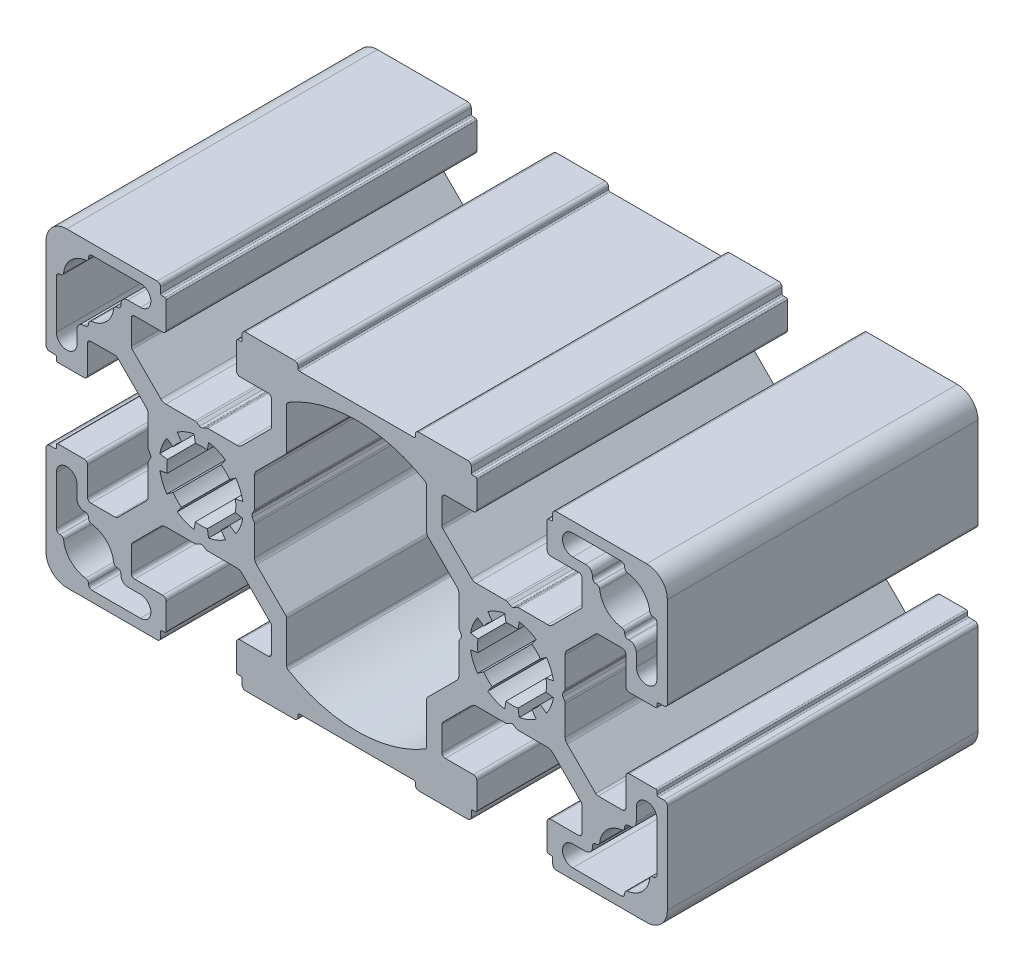
from build123d import *

# Parameters (mm, degrees)
EXTRUDE_2_DEPTH = 45


with BuildPart() as part:
    # Эскиз1 → Бобышка-Вытянуть2 (new body)
    with BuildSketch(Plane.XY):
        with BuildLine():
            Line((-35.141853673, 36.152210307), (-35.141853673, 40.388068593))
            ThreePointArc((-35.141853673, 40.388068593), (-35.21797414, 40.770752026), (-35.434746892, 41.095175374))
            Line((-35.434746892, 41.095175374), (-37.681504654, 43.341933137))
            Line((-37.681504654, 43.341933137), (-39.566246974, 45.226675456))
            ThreePointArc((-39.566246974, 45.226675456), (-39.728458648, 45.335061832), (-39.919800364, 45.373122066))
            Line((-39.919800364, 45.373122066), (-43.441373239, 45.373122066))
            ThreePointArc((-43.441373239, 45.373122066), (-43.79492663, 45.226675456), (-43.941373239, 44.873122066))
            Line((-43.941373239, 44.873122066), (-43.941373239, 40.823122066))
            ThreePointArc((-43.941373239, 40.823122066), (-44.087819849, 40.469568675), (-44.441373239, 40.323122066))
            Line((-44.441373239, 40.323122066), (-48.241373239, 40.323122066))
            ThreePointArc((-48.241373239, 40.323122066), (-48.382794596, 40.381700709), (-48.441373239, 40.523122066))
            Line((-48.441373239, 40.523122066), (-48.441373239, 40.923122066))
            ThreePointArc((-48.441373239, 40.923122066), (-48.499951883, 41.064543422), (-48.641373239, 41.123122066))
            Line((-48.641373239, 41.123122066), (-49.441373239, 41.123122066))
            ThreePointArc((-49.441373239, 41.123122066), (-49.79492663, 41.269568675), (-49.941373239, 41.623122066))
            Line((-49.941373239, 41.623122066), (-49.941373239, 54.723122066))
            ThreePointArc((-49.941373239, 54.723122066), (-49.062693583, 56.844442409), (-46.941373239, 57.723122066))
            Line((-46.941373239, 57.723122066), (-33.841373239, 57.723122066))
            ThreePointArc((-33.841373239, 57.723122066), (-33.487819849, 57.576675456), (-33.341373239, 57.223122066))
            Line((-33.341373239, 57.223122066), (-33.341373239, 56.423122066))
            ThreePointArc((-33.341373239, 56.423122066), (-33.282794596, 56.281700709), (-33.141373239, 56.223122066))
            Line((-33.141373239, 56.223122066), (-32.741373239, 56.223122066))
            ThreePointArc((-32.741373239, 56.223122066), (-32.599951883, 56.164543422), (-32.541373239, 56.023122066))
            Line((-32.541373239, 56.023122066), (-32.541373239, 52.223122066))
            ThreePointArc((-32.541373239, 52.223122066), (-32.687819849, 51.869568675), (-33.041373239, 51.723122066))
            Line((-33.041373239, 51.723122066), (-37.091373239, 51.723122066))
            ThreePointArc((-37.091373239, 51.723122066), (-37.44492663, 51.576675456), (-37.591373239, 51.223122066))
            Line((-37.591373239, 51.223122066), (-37.591373239, 47.70154919))
            ThreePointArc((-37.591373239, 47.70154919), (-37.553313006, 47.510207474), (-37.44492663, 47.3479958))
            Line((-37.44492663, 47.3479958), (-35.560184311, 45.463253481))
            Line((-35.560184311, 45.463253481), (-33.313426548, 43.216495718))
            ThreePointArc((-33.313426548, 43.216495718), (-32.989003199, 42.999722967), (-32.606319767, 42.923602499))
            Line((-32.606319767, 42.923602499), (-28.370461481, 42.923602499))
            ThreePointArc((-28.370461481, 42.923602499), (-28.241051958, 42.906565412), (-28.120461481, 42.856615201))
            Line((-28.120461481, 42.856615201), (-27.691373239, 42.608880989))
            ThreePointArc((-27.691373239, 42.608880989), (-27.441373239, 42.541893691), (-27.191373239, 42.608880989))
            Line((-27.191373239, 42.608880989), (-26.762284998, 42.856615201))
            ThreePointArc((-26.762284998, 42.856615201), (-26.64169452, 42.906565412), (-26.512284998, 42.923602499))
            Line((-26.512284998, 42.923602499), (-22.276426712, 42.923602499))
            ThreePointArc((-22.276426712, 42.923602499), (-21.89374328, 42.999722967), (-21.569319931, 43.216495718))
            Line((-21.569319931, 43.216495718), (-19.322562168, 45.463253481))
            Line((-19.322562168, 45.463253481), (-17.437819849, 47.3479958))
            ThreePointArc((-17.437819849, 47.3479958), (-17.329433473, 47.510207474), (-17.291373239, 47.70154919))
            Line((-17.291373239, 47.70154919), (-17.291373239, 51.223122066))
            ThreePointArc((-17.291373239, 51.223122066), (-17.437819849, 51.576675456), (-17.791373239, 51.723122066))
            Line((-17.791373239, 51.723122066), (-21.841373239, 51.723122066))
            ThreePointArc((-21.841373239, 51.723122066), (-22.19492663, 51.869568675), (-22.341373239, 52.223122066))
            Line((-22.341373239, 52.223122066), (-22.341373239, 56.023122066))
            ThreePointArc((-22.341373239, 56.023122066), (-22.282794596, 56.164543422), (-22.141373239, 56.223122066))
            Line((-22.141373239, 56.223122066), (-21.741373239, 56.223122066))
            ThreePointArc((-21.741373239, 56.223122066), (-21.599951883, 56.281700709), (-21.541373239, 56.423122066))
            Line((-21.541373239, 56.423122066), (-21.541373239, 57.223122066))
            ThreePointArc((-21.541373239, 57.223122066), (-21.39492663, 57.576675456), (-21.041373239, 57.723122066))
            Line((-21.041373239, 57.723122066), (-13.941373239, 57.723122066))
            ThreePointArc((-13.941373239, 57.723122066), (-13.587819849, 57.576675456), (-13.441373239, 57.223122066))
            Line((-13.441373239, 57.223122066), (-13.441373239, 56.923122066))
            ThreePointArc((-13.441373239, 56.923122066), (-13.382794596, 56.781700709), (-13.241373239, 56.723122066))
            Line((-13.241373239, 56.723122066), (3.358626761, 56.723122066))
            ThreePointArc((3.358626761, 56.723122066), (3.500048117, 56.781700709), (3.558626761, 56.923122066))
            Line((3.558626761, 56.923122066), (3.558626761, 57.223122066))
            ThreePointArc((3.558626761, 57.223122066), (3.70507337, 57.576675456), (4.058626761, 57.723122066))
            Line((4.058626761, 57.723122066), (11.158626761, 57.723122066))
            ThreePointArc((11.158626761, 57.723122066), (11.512180151, 57.576675456), (11.658626761, 57.223122066))
            Line((11.658626761, 57.223122066), (11.658626761, 56.423122066))
            ThreePointArc((11.658626761, 56.423122066), (11.717205404, 56.281700709), (11.858626761, 56.223122066))
            Line((11.858626761, 56.223122066), (12.258626761, 56.223122066))
            ThreePointArc((12.258626761, 56.223122066), (12.400048117, 56.164543422), (12.458626761, 56.023122066))
            Line((12.458626761, 56.023122066), (12.458626761, 52.223122066))
            ThreePointArc((12.458626761, 52.223122066), (12.312180151, 51.869568675), (11.958626761, 51.723122066))
            Line((11.958626761, 51.723122066), (7.908626761, 51.723122066))
            ThreePointArc((7.908626761, 51.723122066), (7.55507337, 51.576675456), (7.408626761, 51.223122066))
            Line((7.408626761, 51.223122066), (7.408626761, 47.70154919))
            ThreePointArc((7.408626761, 47.70154919), (7.446686994, 47.510207474), (7.55507337, 47.3479958))
            Line((7.55507337, 47.3479958), (9.439815689, 45.463253481))
            Line((9.439815689, 45.463253481), (11.686573452, 43.216495718))
            ThreePointArc((11.686573452, 43.216495718), (12.010996801, 42.999722967), (12.393680233, 42.923602499))
            Line((12.393680233, 42.923602499), (16.629538519, 42.923602499))
            ThreePointArc((16.629538519, 42.923602499), (16.758948042, 42.906565412), (16.879538519, 42.856615201))
            Line((16.879538519, 42.856615201), (17.308626761, 42.608880989))
            ThreePointArc((17.308626761, 42.608880989), (17.558626761, 42.541893691), (17.808626761, 42.608880989))
            Line((17.808626761, 42.608880989), (18.237715002, 42.856615201))
            ThreePointArc((18.237715002, 42.856615201), (18.35830548, 42.906565412), (18.487715002, 42.923602499))
            Line((18.487715002, 42.923602499), (22.723573288, 42.923602499))
            ThreePointArc((22.723573288, 42.923602499), (23.10625672, 42.999722967), (23.430680069, 43.216495718))
            Line((23.430680069, 43.216495718), (25.677437832, 45.463253481))
            Line((25.677437832, 45.463253481), (27.562180151, 47.3479958))
            ThreePointArc((27.562180151, 47.3479958), (27.670566527, 47.510207474), (27.708626761, 47.70154919))
            Line((27.708626761, 47.70154919), (27.708626761, 51.223122066))
            ThreePointArc((27.708626761, 51.223122066), (27.562180151, 51.576675456), (27.208626761, 51.723122066))
            Line((27.208626761, 51.723122066), (23.158626761, 51.723122066))
            ThreePointArc((23.158626761, 51.723122066), (22.80507337, 51.869568675), (22.658626761, 52.223122066))
            Line((22.658626761, 52.223122066), (22.658626761, 56.023122066))
            ThreePointArc((22.658626761, 56.023122066), (22.717205404, 56.164543422), (22.858626761, 56.223122066))
            Line((22.858626761, 56.223122066), (23.258626761, 56.223122066))
            ThreePointArc((23.258626761, 56.223122066), (23.400048117, 56.281700709), (23.458626761, 56.423122066))
            Line((23.458626761, 56.423122066), (23.458626761, 57.223122066))
            ThreePointArc((23.458626761, 57.223122066), (23.60507337, 57.576675456), (23.958626761, 57.723122066))
            Line((23.958626761, 57.723122066), (37.058626761, 57.723122066))
            ThreePointArc((37.058626761, 57.723122066), (39.179947104, 56.844442409), (40.058626761, 54.723122066))
            Line((40.058626761, 54.723122066), (40.058626761, 41.623122066))
            ThreePointArc((40.058626761, 41.623122066), (39.912180151, 41.269568675), (39.558626761, 41.123122066))
            Line((39.558626761, 41.123122066), (38.758626761, 41.123122066))
            ThreePointArc((38.758626761, 41.123122066), (38.617205404, 41.064543422), (38.558626761, 40.923122066))
            Line((38.558626761, 40.923122066), (38.558626761, 40.523122066))
            ThreePointArc((38.558626761, 40.523122066), (38.500048117, 40.381700709), (38.358626761, 40.323122066))
            Line((38.358626761, 40.323122066), (34.558626761, 40.323122066))
            ThreePointArc((34.558626761, 40.323122066), (34.20507337, 40.469568675), (34.058626761, 40.823122066))
            Line((34.058626761, 40.823122066), (34.058626761, 44.873122066))
            ThreePointArc((34.058626761, 44.873122066), (33.912180151, 45.226675456), (33.558626761, 45.373122066))
            Line((33.558626761, 45.373122066), (30.037053885, 45.373122066))
            ThreePointArc((30.037053885, 45.373122066), (29.845712169, 45.335061832), (29.683500495, 45.226675456))
            Line((29.683500495, 45.226675456), (27.798758175, 43.341933137))
            Line((27.798758175, 43.341933137), (25.552000413, 41.095175374))
            ThreePointArc((25.552000413, 41.095175374), (25.335227661, 40.770752026), (25.259107194, 40.388068593))
            Line((25.259107194, 40.388068593), (25.259107194, 36.152210307))
            ThreePointArc((25.259107194, 36.152210307), (25.242070107, 36.022800785), (25.192119896, 35.902210307))
            Line((25.192119896, 35.902210307), (24.944385684, 35.473122066))
            ThreePointArc((24.944385684, 35.473122066), (24.877398386, 35.223122066), (24.944385684, 34.973122066))
            Line((24.944385684, 34.973122066), (25.192119896, 34.544033824))
            ThreePointArc((25.192119896, 34.544033824), (25.242070107, 34.423443347), (25.259107194, 34.294033824))
            Line((25.259107194, 34.294033824), (25.259107194, 30.058175538))
            ThreePointArc((25.259107194, 30.058175538), (25.335227661, 29.675492106), (25.552000413, 29.351068757))
            Line((25.552000413, 29.351068757), (27.798758175, 27.104310994))
            Line((27.798758175, 27.104310994), (29.683500495, 25.219568675))
            ThreePointArc((29.683500495, 25.219568675), (29.845712169, 25.111182299), (30.037053885, 25.073122066))
            Line((30.037053885, 25.073122066), (33.558626761, 25.073122066))
            ThreePointArc((33.558626761, 25.073122066), (33.912180151, 25.219568675), (34.058626761, 25.573122066))
            Line((34.058626761, 25.573122066), (34.058626761, 29.623122066))
            ThreePointArc((34.058626761, 29.623122066), (34.20507337, 29.976675456), (34.558626761, 30.123122066))
            Line((34.558626761, 30.123122066), (38.358626761, 30.123122066))
            ThreePointArc((38.358626761, 30.123122066), (38.500048117, 30.064543422), (38.558626761, 29.923122066))
            Line((38.558626761, 29.923122066), (38.558626761, 29.523122066))
            ThreePointArc((38.558626761, 29.523122066), (38.617205404, 29.381700709), (38.758626761, 29.323122066))
            Line((38.758626761, 29.323122066), (39.558626761, 29.323122066))
            ThreePointArc((39.558626761, 29.323122066), (39.912180151, 29.176675456), (40.058626761, 28.823122066))
            Line((40.058626761, 28.823122066), (40.058626761, 15.723122066))
            ThreePointArc((40.058626761, 15.723122066), (39.179947104, 13.601801722), (37.058626761, 12.723122066))
            Line((37.058626761, 12.723122066), (23.958626761, 12.723122066))
            ThreePointArc((23.958626761, 12.723122066), (23.60507337, 12.869568675), (23.458626761, 13.223122066))
            Line((23.458626761, 13.223122066), (23.458626761, 14.023122066))
            ThreePointArc((23.458626761, 14.023122066), (23.400048117, 14.164543422), (23.258626761, 14.223122066))
            Line((23.258626761, 14.223122066), (22.858626761, 14.223122066))
            ThreePointArc((22.858626761, 14.223122066), (22.717205404, 14.281700709), (22.658626761, 14.423122066))
            Line((22.658626761, 14.423122066), (22.658626761, 18.223122066))
            ThreePointArc((22.658626761, 18.223122066), (22.80507337, 18.576675456), (23.158626761, 18.723122066))
            Line((23.158626761, 18.723122066), (27.208626761, 18.723122066))
            ThreePointArc((27.208626761, 18.723122066), (27.562180151, 18.869568675), (27.708626761, 19.223122066))
            Line((27.708626761, 19.223122066), (27.708626761, 22.744694941))
            ThreePointArc((27.708626761, 22.744694941), (27.670566527, 22.936036657), (27.562180151, 23.098248332))
            Line((27.562180151, 23.098248332), (25.677437832, 24.982990651))
            Line((25.677437832, 24.982990651), (23.430680069, 27.229748413))
            ThreePointArc((23.430680069, 27.229748413), (23.10625672, 27.446521165), (22.723573288, 27.522641632))
            Line((22.723573288, 27.522641632), (18.487715002, 27.522641632))
            ThreePointArc((18.487715002, 27.522641632), (18.35830548, 27.539678719), (18.237715002, 27.58962893))
            Line((18.237715002, 27.58962893), (17.808626761, 27.837363142))
            ThreePointArc((17.808626761, 27.837363142), (17.558626761, 27.90435044), (17.308626761, 27.837363142))
            Line((17.308626761, 27.837363142), (16.879538519, 27.58962893))
            ThreePointArc((16.879538519, 27.58962893), (16.758948042, 27.539678719), (16.629538519, 27.522641632))
            Line((16.629538519, 27.522641632), (12.393680233, 27.522641632))
            ThreePointArc((12.393680233, 27.522641632), (12.010996801, 27.446521165), (11.686573452, 27.229748413))
            Line((11.686573452, 27.229748413), (9.439815689, 24.982990651))
            Line((9.439815689, 24.982990651), (7.55507337, 23.098248332))
            ThreePointArc((7.55507337, 23.098248332), (7.446686994, 22.936036657), (7.408626761, 22.744694941))
            Line((7.408626761, 22.744694941), (7.408626761, 19.223122066))
            ThreePointArc((7.408626761, 19.223122066), (7.55507337, 18.869568675), (7.908626761, 18.723122066))
            Line((7.908626761, 18.723122066), (11.958626761, 18.723122066))
            ThreePointArc((11.958626761, 18.723122066), (12.312180151, 18.576675456), (12.458626761, 18.223122066))
            Line((12.458626761, 18.223122066), (12.458626761, 14.423122066))
            ThreePointArc((12.458626761, 14.423122066), (12.400048117, 14.281700709), (12.258626761, 14.223122066))
            Line((12.258626761, 14.223122066), (11.858626761, 14.223122066))
            ThreePointArc((11.858626761, 14.223122066), (11.717205404, 14.164543422), (11.658626761, 14.023122066))
            Line((11.658626761, 14.023122066), (11.658626761, 13.223122066))
            ThreePointArc((11.658626761, 13.223122066), (11.512180151, 12.869568675), (11.158626761, 12.723122066))
            Line((11.158626761, 12.723122066), (4.058626761, 12.723122066))
            ThreePointArc((4.058626761, 12.723122066), (3.70507337, 12.869568675), (3.558626761, 13.223122066))
            Line((3.558626761, 13.223122066), (3.558626761, 13.523122066))
            ThreePointArc((3.558626761, 13.523122066), (3.500048117, 13.664543422), (3.358626761, 13.723122066))
            Line((3.358626761, 13.723122066), (-13.241373239, 13.723122066))
            ThreePointArc((-13.241373239, 13.723122066), (-13.382794596, 13.664543422), (-13.441373239, 13.523122066))
            Line((-13.441373239, 13.523122066), (-13.441373239, 13.223122066))
            ThreePointArc((-13.441373239, 13.223122066), (-13.587819849, 12.869568675), (-13.941373239, 12.723122066))
            Line((-13.941373239, 12.723122066), (-21.041373239, 12.723122066))
            ThreePointArc((-21.041373239, 12.723122066), (-21.39492663, 12.869568675), (-21.541373239, 13.223122066))
            Line((-21.541373239, 13.223122066), (-21.541373239, 14.023122066))
            ThreePointArc((-21.541373239, 14.023122066), (-21.599951883, 14.164543422), (-21.741373239, 14.223122066))
            Line((-21.741373239, 14.223122066), (-22.141373239, 14.223122066))
            ThreePointArc((-22.141373239, 14.223122066), (-22.282794596, 14.281700709), (-22.341373239, 14.423122066))
            Line((-22.341373239, 14.423122066), (-22.341373239, 18.223122066))
            ThreePointArc((-22.341373239, 18.223122066), (-22.19492663, 18.576675456), (-21.841373239, 18.723122066))
            Line((-21.841373239, 18.723122066), (-17.791373239, 18.723122066))
            ThreePointArc((-17.791373239, 18.723122066), (-17.437819849, 18.869568675), (-17.291373239, 19.223122066))
            Line((-17.291373239, 19.223122066), (-17.291373239, 22.744694941))
            ThreePointArc((-17.291373239, 22.744694941), (-17.329433473, 22.936036657), (-17.437819849, 23.098248332))
            Line((-17.437819849, 23.098248332), (-19.322562168, 24.982990651))
            Line((-19.322562168, 24.982990651), (-21.569319931, 27.229748413))
            ThreePointArc((-21.569319931, 27.229748413), (-21.89374328, 27.446521165), (-22.276426712, 27.522641632))
            Line((-22.276426712, 27.522641632), (-26.512284998, 27.522641632))
            ThreePointArc((-26.512284998, 27.522641632), (-26.64169452, 27.539678719), (-26.762284998, 27.58962893))
            Line((-26.762284998, 27.58962893), (-27.191373239, 27.837363142))
            ThreePointArc((-27.191373239, 27.837363142), (-27.441373239, 27.90435044), (-27.691373239, 27.837363142))
            Line((-27.691373239, 27.837363142), (-28.120461481, 27.58962893))
            ThreePointArc((-28.120461481, 27.58962893), (-28.241051958, 27.539678719), (-28.370461481, 27.522641632))
            Line((-28.370461481, 27.522641632), (-32.606319767, 27.522641632))
            ThreePointArc((-32.606319767, 27.522641632), (-32.989003199, 27.446521165), (-33.313426548, 27.229748413))
            Line((-33.313426548, 27.229748413), (-35.560184311, 24.982990651))
            Line((-35.560184311, 24.982990651), (-37.44492663, 23.098248332))
            ThreePointArc((-37.44492663, 23.098248332), (-37.553313006, 22.936036657), (-37.591373239, 22.744694941))
            Line((-37.591373239, 22.744694941), (-37.591373239, 19.223122066))
            ThreePointArc((-37.591373239, 19.223122066), (-37.44492663, 18.869568675), (-37.091373239, 18.723122066))
            Line((-37.091373239, 18.723122066), (-33.041373239, 18.723122066))
            ThreePointArc((-33.041373239, 18.723122066), (-32.687819849, 18.576675456), (-32.541373239, 18.223122066))
            Line((-32.541373239, 18.223122066), (-32.541373239, 14.423122066))
            ThreePointArc((-32.541373239, 14.423122066), (-32.599951883, 14.281700709), (-32.741373239, 14.223122066))
            Line((-32.741373239, 14.223122066), (-33.141373239, 14.223122066))
            ThreePointArc((-33.141373239, 14.223122066), (-33.282794596, 14.164543422), (-33.341373239, 14.023122066))
            Line((-33.341373239, 14.023122066), (-33.341373239, 13.223122066))
            ThreePointArc((-33.341373239, 13.223122066), (-33.487819849, 12.869568675), (-33.841373239, 12.723122066))
            Line((-33.841373239, 12.723122066), (-46.941373239, 12.723122066))
            ThreePointArc((-46.941373239, 12.723122066), (-49.062693583, 13.601801722), (-49.941373239, 15.723122066))
            Line((-49.941373239, 15.723122066), (-49.941373239, 28.823122066))
            ThreePointArc((-49.941373239, 28.823122066), (-49.79492663, 29.176675456), (-49.441373239, 29.323122066))
            Line((-49.441373239, 29.323122066), (-48.641373239, 29.323122066))
            ThreePointArc((-48.641373239, 29.323122066), (-48.499951883, 29.381700709), (-48.441373239, 29.523122066))
            Line((-48.441373239, 29.523122066), (-48.441373239, 29.923122066))
            ThreePointArc((-48.441373239, 29.923122066), (-48.382794596, 30.064543422), (-48.241373239, 30.123122066))
            Line((-48.241373239, 30.123122066), (-44.441373239, 30.123122066))
            ThreePointArc((-44.441373239, 30.123122066), (-44.087819849, 29.976675456), (-43.941373239, 29.623122066))
            Line((-43.941373239, 29.623122066), (-43.941373239, 25.573122066))
            ThreePointArc((-43.941373239, 25.573122066), (-43.79492663, 25.219568675), (-43.441373239, 25.073122066))
            Line((-43.441373239, 25.073122066), (-39.919800364, 25.073122066))
            ThreePointArc((-39.919800364, 25.073122066), (-39.728458648, 25.111182299), (-39.566246974, 25.219568675))
            Line((-39.566246974, 25.219568675), (-37.681504654, 27.104310994))
            Line((-37.681504654, 27.104310994), (-35.434746892, 29.351068757))
            ThreePointArc((-35.434746892, 29.351068757), (-35.21797414, 29.675492106), (-35.141853673, 30.058175538))
            Line((-35.141853673, 30.058175538), (-35.141853673, 34.294033824))
            ThreePointArc((-35.141853673, 34.294033824), (-35.124816586, 34.423443347), (-35.074866375, 34.544033824))
            Line((-35.074866375, 34.544033824), (-34.827132163, 34.973122066))
            ThreePointArc((-34.827132163, 34.973122066), (-34.760144865, 35.223122066), (-34.827132163, 35.473122066))
            Line((-34.827132163, 35.473122066), (-35.074866375, 35.902210307))
            ThreePointArc((-35.074866375, 35.902210307), (-35.124816586, 36.022800785), (-35.141853673, 36.152210307))
        make_face()
        with BuildLine():
            Line((-48.441373239, 51.048122066), (-48.441373239, 44.031073139))
            ThreePointArc((-48.441373239, 44.031073139), (-46.941373239, 42.531073139), (-45.441373239, 44.031073139))
            Line((-45.441373239, 44.031073139), (-45.441373239, 45.873122066))
            ThreePointArc((-45.441373239, 45.873122066), (-45.148480021, 46.580228847), (-44.441373239, 46.873122066))
            Line((-44.441373239, 46.873122066), (-44.266373239, 46.873122066))
            ThreePointArc((-44.266373239, 46.873122066), (-43.912819849, 47.019568675), (-43.766373239, 47.373122066))
            Line((-43.766373239, 47.373122066), (-43.766373239, 47.428352655))
            ThreePointArc((-43.766373239, 47.428352655), (-43.64061947, 47.759924305), (-43.326614203, 47.924710415))
            ThreePointArc((-43.326614203, 47.924710415), (-41.185433488, 48.967182314), (-40.142961589, 51.10836303))
            ThreePointArc((-40.142961589, 51.10836303), (-39.978175478, 51.422368296), (-39.646603828, 51.548122066))
            Line((-39.646603828, 51.548122066), (-39.591373239, 51.548122066))
            ThreePointArc((-39.591373239, 51.548122066), (-39.237819849, 51.694568675), (-39.091373239, 52.048122066))
            Line((-39.091373239, 52.048122066), (-39.091373239, 52.223122066))
            ThreePointArc((-39.091373239, 52.223122066), (-38.798480021, 52.930228847), (-38.091373239, 53.223122066))
            Line((-38.091373239, 53.223122066), (-36.249324313, 53.223122066))
            ThreePointArc((-36.249324313, 53.223122066), (-34.749324313, 54.723122066), (-36.249324313, 56.223122066))
            Line((-36.249324313, 56.223122066), (-43.266373239, 56.223122066))
            ThreePointArc((-43.266373239, 56.223122066), (-43.61992663, 56.076675456), (-43.766373239, 55.723122066))
            Line((-43.766373239, 55.723122066), (-43.766373239, 55.667891477))
            ThreePointArc((-43.766373239, 55.667891477), (-43.892127009, 55.336319827), (-44.206132276, 55.171533716))
            ThreePointArc((-44.206132276, 55.171533716), (-46.347312991, 54.129061817), (-47.38978489, 51.987881102))
            ThreePointArc((-47.38978489, 51.987881102), (-47.554571001, 51.673875835), (-47.88614265, 51.548122066))
            Line((-47.88614265, 51.548122066), (-47.941373239, 51.548122066))
            ThreePointArc((-47.941373239, 51.548122066), (-48.29492663, 51.401675456), (-48.441373239, 51.048122066))
        make_face(mode=Mode.SUBTRACT)
        with BuildLine():
            Line((-43.266373239, 14.223122066), (-36.249324313, 14.223122066))
            ThreePointArc((-36.249324313, 14.223122066), (-34.749324313, 15.723122066), (-36.249324313, 17.223122066))
            Line((-36.249324313, 17.223122066), (-38.091373239, 17.223122066))
            ThreePointArc((-38.091373239, 17.223122066), (-38.798480021, 17.516015285), (-39.091373239, 18.223122066))
            Line((-39.091373239, 18.223122066), (-39.091373239, 18.398122066))
            ThreePointArc((-39.091373239, 18.398122066), (-39.237819849, 18.751675456), (-39.591373239, 18.898122066))
            Line((-39.591373239, 18.898122066), (-39.646603828, 18.898122066))
            ThreePointArc((-39.646603828, 18.898122066), (-39.978175478, 19.023875835), (-40.142961589, 19.337881102))
            ThreePointArc((-40.142961589, 19.337881102), (-41.185433488, 21.479061817), (-43.326614203, 22.521533716))
            ThreePointArc((-43.326614203, 22.521533716), (-43.64061947, 22.686319827), (-43.766373239, 23.017891477))
            Line((-43.766373239, 23.017891477), (-43.766373239, 23.073122066))
            ThreePointArc((-43.766373239, 23.073122066), (-43.912819849, 23.426675456), (-44.266373239, 23.573122066))
            Line((-44.266373239, 23.573122066), (-44.441373239, 23.573122066))
            ThreePointArc((-44.441373239, 23.573122066), (-45.148480021, 23.866015285), (-45.441373239, 24.573122066))
            Line((-45.441373239, 24.573122066), (-45.441373239, 26.415170992))
            ThreePointArc((-45.441373239, 26.415170992), (-46.941373239, 27.915170992), (-48.441373239, 26.415170992))
            Line((-48.441373239, 26.415170992), (-48.441373239, 19.398122066))
            ThreePointArc((-48.441373239, 19.398122066), (-48.29492663, 19.044568675), (-47.941373239, 18.898122066))
            Line((-47.941373239, 18.898122066), (-47.88614265, 18.898122066))
            ThreePointArc((-47.88614265, 18.898122066), (-47.554571001, 18.772368296), (-47.38978489, 18.45836303))
            ThreePointArc((-47.38978489, 18.45836303), (-46.347312991, 16.317182314), (-44.206132276, 15.274710415))
            ThreePointArc((-44.206132276, 15.274710415), (-43.892127009, 15.109924305), (-43.766373239, 14.778352655))
            Line((-43.766373239, 14.778352655), (-43.766373239, 14.723122066))
            ThreePointArc((-43.766373239, 14.723122066), (-43.61992663, 14.369568675), (-43.266373239, 14.223122066))
        make_face(mode=Mode.SUBTRACT)
        with BuildLine():
            Line((-15.091373239, 49.462335628), (-15.091373239, 45.658908503))
            ThreePointArc((-15.091373239, 45.658908503), (-15.129433473, 45.467566787), (-15.237819849, 45.305355113))
            Line((-15.237819849, 45.305355113), (-17.201241825, 43.341933137))
            Line((-17.201241825, 43.341933137), (-19.447999587, 41.095175374))
            ThreePointArc((-19.447999587, 41.095175374), (-19.664772339, 40.770752026), (-19.740892806, 40.388068593))
            Line((-19.740892806, 40.388068593), (-19.740892806, 36.152210307))
            ThreePointArc((-19.740892806, 36.152210307), (-19.757929893, 36.022800785), (-19.807880104, 35.902210307))
            Line((-19.807880104, 35.902210307), (-20.055614316, 35.473122066))
            ThreePointArc((-20.055614316, 35.473122066), (-20.122601614, 35.223122066), (-20.055614316, 34.973122066))
            Line((-20.055614316, 34.973122066), (-19.807880104, 34.544033824))
            ThreePointArc((-19.807880104, 34.544033824), (-19.757929893, 34.423443347), (-19.740892806, 34.294033824))
            Line((-19.740892806, 34.294033824), (-19.740892806, 30.058175538))
            ThreePointArc((-19.740892806, 30.058175538), (-19.664772339, 29.675492106), (-19.447999587, 29.351068757))
            Line((-19.447999587, 29.351068757), (-17.201241825, 27.104310994))
            Line((-17.201241825, 27.104310994), (-15.237819849, 25.140889019))
            ThreePointArc((-15.237819849, 25.140889019), (-15.129433473, 24.978677344), (-15.091373239, 24.787335628))
            Line((-15.091373239, 24.787335628), (-15.091373239, 20.983908503))
            Line((-15.091373239, 20.983908503), (-15.091373239, 18.856158389))
            ThreePointArc((-15.091373239, 18.856158389), (-15.025523953, 18.608139926), (-14.845320608, 18.425448818))
            ThreePointArc((-14.845320608, 18.425448818), (-4.941373239, 15.723122066), (4.962574129, 18.425448818))
            ThreePointArc((4.962574129, 18.425448818), (5.142777474, 18.608139926), (5.208626761, 18.856158389))
            Line((5.208626761, 18.856158389), (5.208626761, 20.983908503))
            Line((5.208626761, 20.983908503), (5.208626761, 24.787335628))
            ThreePointArc((5.208626761, 24.787335628), (5.246686994, 24.978677344), (5.35507337, 25.140889019))
            Line((5.35507337, 25.140889019), (7.318495346, 27.104310994))
            Line((7.318495346, 27.104310994), (9.565253108, 29.351068757))
            ThreePointArc((9.565253108, 29.351068757), (9.78202586, 29.675492106), (9.858146327, 30.058175538))
            Line((9.858146327, 30.058175538), (9.858146327, 34.294033824))
            ThreePointArc((9.858146327, 34.294033824), (9.875183414, 34.423443347), (9.925133625, 34.544033824))
            Line((9.925133625, 34.544033824), (10.172867837, 34.973122066))
            ThreePointArc((10.172867837, 34.973122066), (10.239855135, 35.223122066), (10.172867837, 35.473122066))
            Line((10.172867837, 35.473122066), (9.925133625, 35.902210307))
            ThreePointArc((9.925133625, 35.902210307), (9.875183414, 36.022800785), (9.858146327, 36.152210307))
            Line((9.858146327, 36.152210307), (9.858146327, 40.388068593))
            ThreePointArc((9.858146327, 40.388068593), (9.78202586, 40.770752026), (9.565253108, 41.095175374))
            Line((9.565253108, 41.095175374), (7.318495346, 43.341933137))
            Line((7.318495346, 43.341933137), (5.35507337, 45.305355113))
            ThreePointArc((5.35507337, 45.305355113), (5.246686994, 45.467566787), (5.208626761, 45.658908503))
            Line((5.208626761, 45.658908503), (5.208626761, 49.462335628))
            Line((5.208626761, 49.462335628), (5.208626761, 51.590085743))
            ThreePointArc((5.208626761, 51.590085743), (5.142777474, 51.838104205), (4.962574129, 52.020795313))
            ThreePointArc((4.962574129, 52.020795313), (-4.941373239, 54.723122066), (-14.845320608, 52.020795313))
            ThreePointArc((-14.845320608, 52.020795313), (-15.025523953, 51.838104205), (-15.091373239, 51.590085743))
            Line((-15.091373239, 51.590085743), (-15.091373239, 49.462335628))
        make_face(mode=Mode.SUBTRACT)
        with BuildLine():
            Line((-30.309255421, 39.318882287), (-30.940189501, 40.219949536))
            ThreePointArc((-30.940189501, 40.219949536), (-29.775742177, 40.858787214), (-28.500627123, 41.230449359))
            Line((-28.500627123, 41.230449359), (-28.309614128, 40.147160831))
            ThreePointArc((-28.309614128, 40.147160831), (-27.441373239, 40.223122066), (-26.573132351, 40.147160831))
            Line((-26.573132351, 40.147160831), (-26.382119356, 41.230449359))
            ThreePointArc((-26.382119356, 41.230449359), (-25.107004302, 40.858787214), (-23.942556978, 40.219949536))
            Line((-23.942556978, 40.219949536), (-24.573491058, 39.318882287))
            ThreePointArc((-24.573491058, 39.318882287), (-23.905839334, 38.758655972), (-23.345613018, 38.091004247))
            Line((-23.345613018, 38.091004247), (-22.444545769, 38.721938327))
            ThreePointArc((-22.444545769, 38.721938327), (-21.805708091, 37.557491003), (-21.434045946, 36.282375949))
            Line((-21.434045946, 36.282375949), (-22.517334474, 36.091362954))
            ThreePointArc((-22.517334474, 36.091362954), (-22.441373239, 35.223122066), (-22.517334474, 34.354881177))
            Line((-22.517334474, 34.354881177), (-21.434045946, 34.163868182))
            ThreePointArc((-21.434045946, 34.163868182), (-21.805708091, 32.888753128), (-22.444545769, 31.724305804))
            Line((-22.444545769, 31.724305804), (-23.345613018, 32.355239884))
            ThreePointArc((-23.345613018, 32.355239884), (-23.905839334, 31.68758816), (-24.573491058, 31.127361844))
            Line((-24.573491058, 31.127361844), (-23.942556978, 30.226294596))
            ThreePointArc((-23.942556978, 30.226294596), (-25.107004302, 29.587456917), (-26.382119356, 29.215794772))
            Line((-26.382119356, 29.215794772), (-26.573132351, 30.299083301))
            ThreePointArc((-26.573132351, 30.299083301), (-27.441373239, 30.223122066), (-28.309614128, 30.299083301))
            Line((-28.309614128, 30.299083301), (-28.500627123, 29.215794772))
            ThreePointArc((-28.500627123, 29.215794772), (-29.775742177, 29.587456917), (-30.940189501, 30.226294596))
            Line((-30.940189501, 30.226294596), (-30.309255421, 31.127361844))
            ThreePointArc((-30.309255421, 31.127361844), (-30.976907145, 31.68758816), (-31.537133461, 32.355239884))
            Line((-31.537133461, 32.355239884), (-32.43820071, 31.724305804))
            ThreePointArc((-32.43820071, 31.724305804), (-33.077038388, 32.888753128), (-33.448700533, 34.163868182))
            Line((-33.448700533, 34.163868182), (-32.365412004, 34.354881177))
            ThreePointArc((-32.365412004, 34.354881177), (-32.441373239, 35.223122066), (-32.365412004, 36.091362954))
            Line((-32.365412004, 36.091362954), (-33.448700533, 36.282375949))
            ThreePointArc((-33.448700533, 36.282375949), (-33.077038388, 37.557491003), (-32.43820071, 38.721938327))
            Line((-32.43820071, 38.721938327), (-31.537133461, 38.091004247))
            ThreePointArc((-31.537133461, 38.091004247), (-30.976907145, 38.758655972), (-30.309255421, 39.318882287))
        make_face(mode=Mode.SUBTRACT)
        with BuildLine():
            Line((38.558626761, 19.398122066), (38.558626761, 26.415170992))
            ThreePointArc((38.558626761, 26.415170992), (37.058626761, 27.915170992), (35.558626761, 26.415170992))
            Line((35.558626761, 26.415170992), (35.558626761, 24.573122066))
            ThreePointArc((35.558626761, 24.573122066), (35.265733542, 23.866015285), (34.558626761, 23.573122066))
            Line((34.558626761, 23.573122066), (34.383626761, 23.573122066))
            ThreePointArc((34.383626761, 23.573122066), (34.03007337, 23.426675456), (33.883626761, 23.073122066))
            Line((33.883626761, 23.073122066), (33.883626761, 23.017891477))
            ThreePointArc((33.883626761, 23.017891477), (33.757872991, 22.686319827), (33.443867724, 22.521533716))
            ThreePointArc((33.443867724, 22.521533716), (31.302687009, 21.479061817), (30.26021511, 19.337881102))
            ThreePointArc((30.26021511, 19.337881102), (30.095428999, 19.023875835), (29.76385735, 18.898122066))
            Line((29.76385735, 18.898122066), (29.708626761, 18.898122066))
            ThreePointArc((29.708626761, 18.898122066), (29.35507337, 18.751675456), (29.208626761, 18.398122066))
            Line((29.208626761, 18.398122066), (29.208626761, 18.223122066))
            ThreePointArc((29.208626761, 18.223122066), (28.915733542, 17.516015285), (28.208626761, 17.223122066))
            Line((28.208626761, 17.223122066), (26.366577834, 17.223122066))
            ThreePointArc((26.366577834, 17.223122066), (24.866577834, 15.723122066), (26.366577834, 14.223122066))
            Line((26.366577834, 14.223122066), (33.383626761, 14.223122066))
            ThreePointArc((33.383626761, 14.223122066), (33.737180151, 14.369568675), (33.883626761, 14.723122066))
            Line((33.883626761, 14.723122066), (33.883626761, 14.778352655))
            ThreePointArc((33.883626761, 14.778352655), (34.00938053, 15.109924305), (34.323385797, 15.274710415))
            ThreePointArc((34.323385797, 15.274710415), (36.464566512, 16.317182314), (37.507038411, 18.45836303))
            ThreePointArc((37.507038411, 18.45836303), (37.671824522, 18.772368296), (38.003396172, 18.898122066))
            Line((38.003396172, 18.898122066), (38.058626761, 18.898122066))
            ThreePointArc((38.058626761, 18.898122066), (38.412180151, 19.044568675), (38.558626761, 19.398122066))
        make_face(mode=Mode.SUBTRACT)
        with BuildLine():
            Line((20.426508942, 31.127361844), (21.057443022, 30.226294596))
            ThreePointArc((21.057443022, 30.226294596), (19.892995698, 29.587456917), (18.617880644, 29.215794772))
            Line((18.617880644, 29.215794772), (18.426867649, 30.299083301))
            ThreePointArc((18.426867649, 30.299083301), (17.558626761, 30.223122066), (16.690385872, 30.299083301))
            Line((16.690385872, 30.299083301), (16.499372877, 29.215794772))
            ThreePointArc((16.499372877, 29.215794772), (15.224257823, 29.587456917), (14.059810499, 30.226294596))
            Line((14.059810499, 30.226294596), (14.690744579, 31.127361844))
            ThreePointArc((14.690744579, 31.127361844), (14.023092855, 31.68758816), (13.462866539, 32.355239884))
            Line((13.462866539, 32.355239884), (12.56179929, 31.724305804))
            ThreePointArc((12.56179929, 31.724305804), (11.922961612, 32.888753128), (11.551299467, 34.163868182))
            Line((11.551299467, 34.163868182), (12.634587996, 34.354881177))
            ThreePointArc((12.634587996, 34.354881177), (12.558626761, 35.223122066), (12.634587996, 36.091362954))
            Line((12.634587996, 36.091362954), (11.551299467, 36.282375949))
            ThreePointArc((11.551299467, 36.282375949), (11.922961612, 37.557491003), (12.56179929, 38.721938327))
            Line((12.56179929, 38.721938327), (13.462866539, 38.091004247))
            ThreePointArc((13.462866539, 38.091004247), (14.023092855, 38.758655972), (14.690744579, 39.318882287))
            Line((14.690744579, 39.318882287), (14.059810499, 40.219949536))
            ThreePointArc((14.059810499, 40.219949536), (15.224257823, 40.858787214), (16.499372877, 41.230449359))
            Line((16.499372877, 41.230449359), (16.690385872, 40.147160831))
            ThreePointArc((16.690385872, 40.147160831), (17.558626761, 40.223122066), (18.426867649, 40.147160831))
            Line((18.426867649, 40.147160831), (18.617880644, 41.230449359))
            ThreePointArc((18.617880644, 41.230449359), (19.892995698, 40.858787214), (21.057443022, 40.219949536))
            Line((21.057443022, 40.219949536), (20.426508942, 39.318882287))
            ThreePointArc((20.426508942, 39.318882287), (21.094160666, 38.758655972), (21.654386982, 38.091004247))
            Line((21.654386982, 38.091004247), (22.555454231, 38.721938327))
            ThreePointArc((22.555454231, 38.721938327), (23.194291909, 37.557491003), (23.565954054, 36.282375949))
            Line((23.565954054, 36.282375949), (22.482665526, 36.091362954))
            ThreePointArc((22.482665526, 36.091362954), (22.558626761, 35.223122066), (22.482665526, 34.354881177))
            Line((22.482665526, 34.354881177), (23.565954054, 34.163868182))
            ThreePointArc((23.565954054, 34.163868182), (23.194291909, 32.888753128), (22.555454231, 31.724305804))
            Line((22.555454231, 31.724305804), (21.654386982, 32.355239884))
            ThreePointArc((21.654386982, 32.355239884), (21.094160666, 31.68758816), (20.426508942, 31.127361844))
        make_face(mode=Mode.SUBTRACT)
        with BuildLine():
            Line((33.383626761, 56.223122066), (26.366577834, 56.223122066))
            ThreePointArc((26.366577834, 56.223122066), (24.866577834, 54.723122066), (26.366577834, 53.223122066))
            Line((26.366577834, 53.223122066), (28.208626761, 53.223122066))
            ThreePointArc((28.208626761, 53.223122066), (28.915733542, 52.930228847), (29.208626761, 52.223122066))
            Line((29.208626761, 52.223122066), (29.208626761, 52.048122066))
            ThreePointArc((29.208626761, 52.048122066), (29.35507337, 51.694568675), (29.708626761, 51.548122066))
            Line((29.708626761, 51.548122066), (29.76385735, 51.548122066))
            ThreePointArc((29.76385735, 51.548122066), (30.095428999, 51.422368296), (30.26021511, 51.10836303))
            ThreePointArc((30.26021511, 51.10836303), (31.302687009, 48.967182314), (33.443867724, 47.924710415))
            ThreePointArc((33.443867724, 47.924710415), (33.757872991, 47.759924305), (33.883626761, 47.428352655))
            Line((33.883626761, 47.428352655), (33.883626761, 47.373122066))
            ThreePointArc((33.883626761, 47.373122066), (34.03007337, 47.019568675), (34.383626761, 46.873122066))
            Line((34.383626761, 46.873122066), (34.558626761, 46.873122066))
            ThreePointArc((34.558626761, 46.873122066), (35.265733542, 46.580228847), (35.558626761, 45.873122066))
            Line((35.558626761, 45.873122066), (35.558626761, 44.031073139))
            ThreePointArc((35.558626761, 44.031073139), (37.058626761, 42.531073139), (38.558626761, 44.031073139))
            Line((38.558626761, 44.031073139), (38.558626761, 51.048122066))
            ThreePointArc((38.558626761, 51.048122066), (38.412180151, 51.401675456), (38.058626761, 51.548122066))
            Line((38.058626761, 51.548122066), (38.003396172, 51.548122066))
            ThreePointArc((38.003396172, 51.548122066), (37.671824522, 51.673875835), (37.507038411, 51.987881102))
            ThreePointArc((37.507038411, 51.987881102), (36.464566512, 54.129061817), (34.323385797, 55.171533716))
            ThreePointArc((34.323385797, 55.171533716), (34.00938053, 55.336319827), (33.883626761, 55.667891477))
            Line((33.883626761, 55.667891477), (33.883626761, 55.723122066))
            ThreePointArc((33.883626761, 55.723122066), (33.737180151, 56.076675456), (33.383626761, 56.223122066))
        make_face(mode=Mode.SUBTRACT)
    extrude(amount=EXTRUDE_2_DEPTH)


solid = part.part
